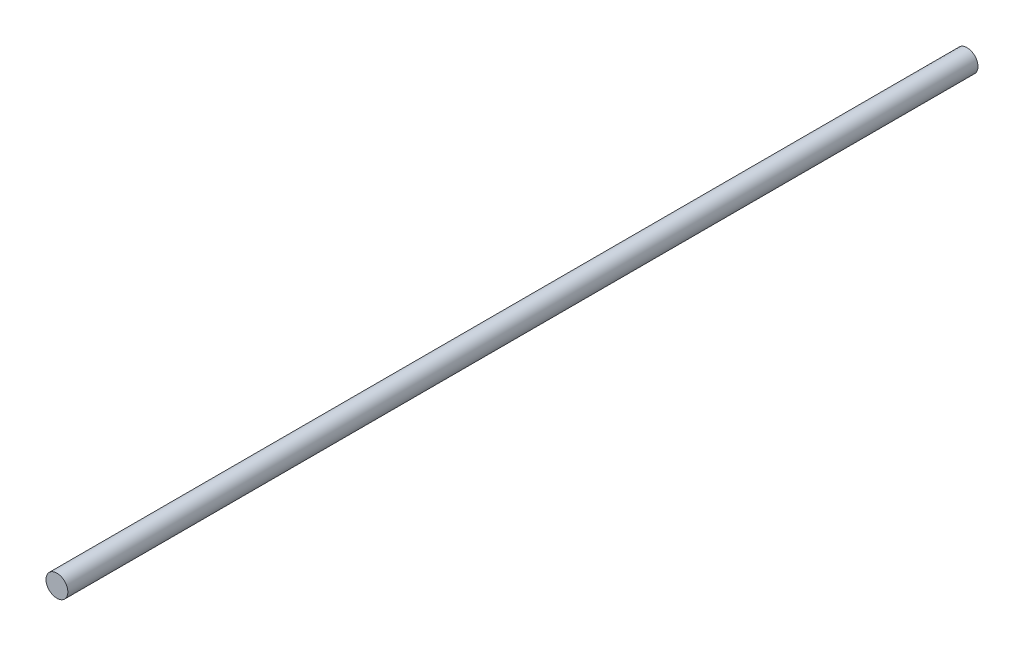
from build123d import *

# Parameters (mm, degrees)
SKETCH1_R           = 6
BOSS_EXTRUDE1_DEPTH = 500


with BuildPart() as part:
    # Sketch1 → Boss-Extrude1 (new body)
    with BuildSketch(Plane.XY):
        Circle(SKETCH1_R)
    extrude(amount=BOSS_EXTRUDE1_DEPTH)


solid = part.part
